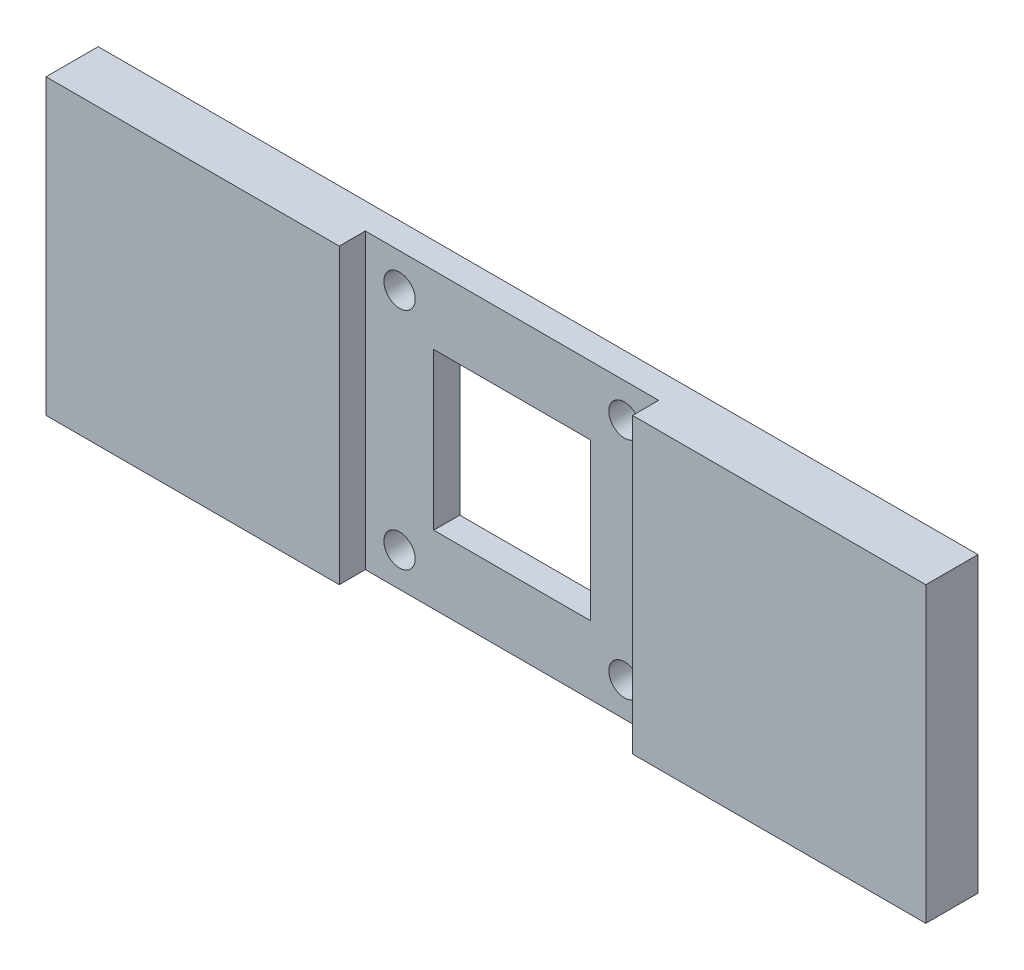
from build123d import *

# Parameters (mm, degrees)
SKETCH1_W           = 350
SKETCH1_H           = 56.2
BOSS_EXTRUDE1_DEPTH = 10
SKETCH2_W           = 56.2
SKETCH2_H           = 56.2
CUT_EXTRUDE1_DEPTH  = 5
SKETCH3_W           = 10
SKETCH3_H           = 56.2
BOSS_EXTRUDE2_DEPTH = 10
SKETCH4_W           = 10
SKETCH4_H           = 56.2
BOSS_EXTRUDE3_DEPTH = 10
CUT_EXTRUDE2_DEPTH  = 56.2
SKETCH6_W           = 10
SKETCH6_H           = 56.2
BOSS_EXTRUDE4_DEPTH = 10
SKETCH7_W           = 10
SKETCH7_H           = 56.2
BOSS_EXTRUDE5_DEPTH = 10
CUT_EXTRUDE3_DEPTH  = 56.2
SKETCH9_W           = 30
SKETCH9_H           = 30
CUT_EXTRUDE4_DEPTH  = 5
SKETCH10_R          = 3
CUT_EXTRUDE5_DEPTH  = 5
SKETCH11_W          = 2.5
SKETCH11_H          = 15
CUT_EXTRUDE6_DEPTH  = 7
SKETCH12_W          = 2.5
SKETCH12_H          = 15
CUT_EXTRUDE7_DEPTH  = 7
SKETCH13_W          = 100.7
SKETCH13_H          = 56.2
CUT_EXTRUDE9_DEPTH  = 10


with BuildPart() as part:
    # Sketch1 → Boss-Extrude1 (new body)
    with BuildSketch(Plane.XY):
        Rectangle(SKETCH1_W, SKETCH1_H)
    extrude(amount=BOSS_EXTRUDE1_DEPTH)

    # Sketch2 → Cut-Extrude1 (cut)
    with BuildSketch(Plane.XY.offset(10)):
        Rectangle(SKETCH2_W, SKETCH2_H)
    extrude(amount=-CUT_EXTRUDE1_DEPTH, mode=Mode.SUBTRACT)

    # Sketch3 → Boss-Extrude2 (add)
    with BuildSketch(Plane(origin=(175, 0, 0), x_dir=(0, 0, -1), z_dir=(1, 0, 0))):
        with Locations((-5, 0)):
            Rectangle(SKETCH3_W, SKETCH3_H)
    extrude(amount=BOSS_EXTRUDE2_DEPTH)

    # Sketch4 → Boss-Extrude3 (add)
    with BuildSketch(Plane.XY.offset(10)):
        with Locations((180, 0)):
            Rectangle(SKETCH4_W, SKETCH4_H)
    extrude(amount=BOSS_EXTRUDE3_DEPTH)

    # Sketch5 → Cut-Extrude2 (cut)
    with BuildSketch(Plane(origin=(0, 28.1, 0), x_dir=(1, 0, 0), z_dir=(0, 1, 0))):
        Polygon((175, -20), (185, -10), (185, -20), align=None)
    extrude(amount=-CUT_EXTRUDE2_DEPTH, mode=Mode.SUBTRACT)

    # Sketch6 → Boss-Extrude4 (add)
    with BuildSketch(Plane.ZY.offset(175)):
        with Locations((5, 0)):
            Rectangle(SKETCH6_W, SKETCH6_H)
    extrude(amount=BOSS_EXTRUDE4_DEPTH)

    # Sketch7 → Boss-Extrude5 (add)
    with BuildSketch(Plane.XY.offset(10)):
        with Locations((-180, 0)):
            Rectangle(SKETCH7_W, SKETCH7_H)
    extrude(amount=BOSS_EXTRUDE5_DEPTH)

    # Sketch8 → Cut-Extrude3 (cut)
    with BuildSketch(Plane(origin=(0, 28.1, 0), x_dir=(1, 0, 0), z_dir=(0, 1, 0))):
        Polygon((-175, -20), (-185, -10), (-185, -20), align=None)
    extrude(amount=-CUT_EXTRUDE3_DEPTH, mode=Mode.SUBTRACT)

    # Sketch9 → Cut-Extrude4 (cut)
    with BuildSketch(Plane.XY.offset(5)):
        Rectangle(SKETCH9_W, SKETCH9_H)
    extrude(amount=-CUT_EXTRUDE4_DEPTH, mode=Mode.SUBTRACT)

    # Sketch10 → Cut-Extrude5 (cut)
    with BuildSketch(Plane.XY.offset(5)):
        with Locations((21.55, 21.55)):
            Circle(SKETCH10_R)
        with Locations((-21.55, -21.55)):
            Circle(SKETCH10_R)
        with Locations((-21.55, 21.55)):
            Circle(SKETCH10_R)
        with Locations((21.55, -21.55)):
            Circle(SKETCH10_R)
    extrude(amount=-CUT_EXTRUDE5_DEPTH, mode=Mode.SUBTRACT)

    # Sketch11 → Cut-Extrude6 (cut)
    with BuildSketch(Plane(origin=(97.5, 0, 97.5), x_dir=(0.7071067811865478, 0, -0.7071067811865472), z_dir=(0.7071067811865472, 0, 0.7071067811865478))):
        with Locations((116.672618896, 0)):
            Rectangle(SKETCH11_W, SKETCH11_H)
    extrude(amount=-CUT_EXTRUDE6_DEPTH, mode=Mode.SUBTRACT)

    # Sketch12 → Cut-Extrude7 (cut)
    with BuildSketch(Plane(origin=(-97.5, 0, 97.5), x_dir=(0.7071067811865478, 0, 0.7071067811865472), z_dir=(-0.7071067811865472, 0, 0.7071067811865478))):
        with Locations((-116.672618896, 0)):
            Rectangle(SKETCH12_W, SKETCH12_H)
    extrude(amount=-CUT_EXTRUDE7_DEPTH, mode=Mode.SUBTRACT)

    # Sketch13 → Cut-Extrude9 (cut)
    with BuildSketch(Plane.XY.offset(10)):
        with Locations((-134.65, 0)):
            Rectangle(SKETCH13_W, SKETCH13_H)
        with Locations((134.65, 0)):
            Rectangle(SKETCH13_W, SKETCH13_H)
    extrude(amount=-CUT_EXTRUDE9_DEPTH, mode=Mode.SUBTRACT)


with BuildPart() as body_2:
    # of the pieces the cut leaves, the one that is kept (cut_extrude9_keep)
    add(part.part.solids().sort_by_distance((-84.3, -28.1, 0))[0])


solid = body_2.part
